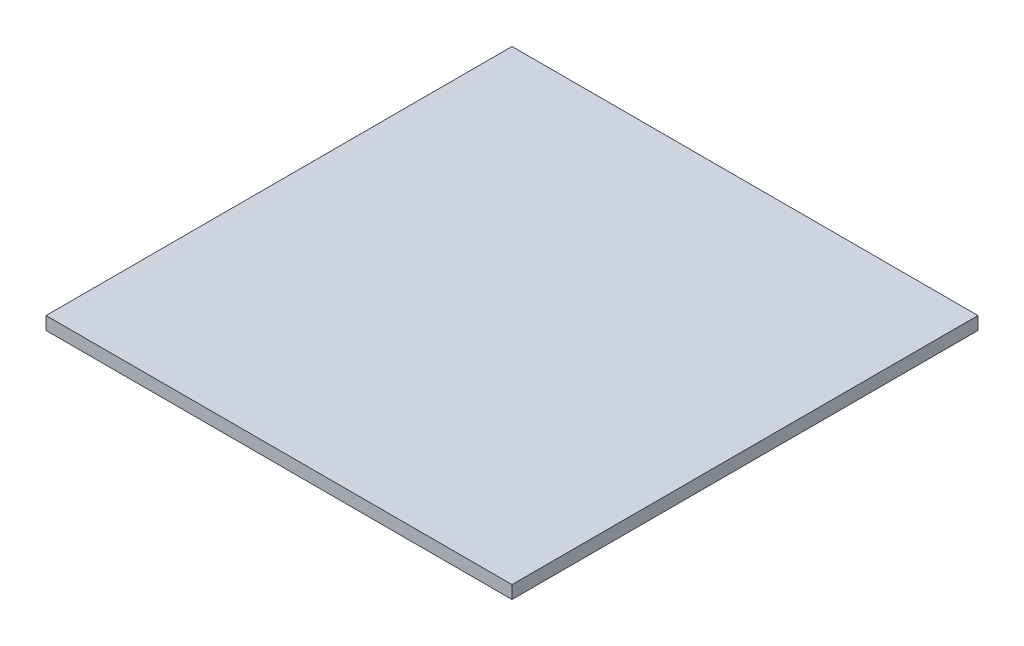
from build123d import *

# Parameters (mm, degrees)
SKETCH_1_W      = 360
SKETCH_1_H      = 360
EXTRUDE_1_DEPTH = 10


with BuildPart() as part:
    # Эскиз1 → Бобышка-Вытянуть1 (new body)
    with BuildSketch(Plane(origin=(0, 0, 0), x_dir=(1, 0, 0), z_dir=(0, 1, 0))):
        Rectangle(SKETCH_1_W, SKETCH_1_H)
    extrude(amount=EXTRUDE_1_DEPTH)


solid = part.part
